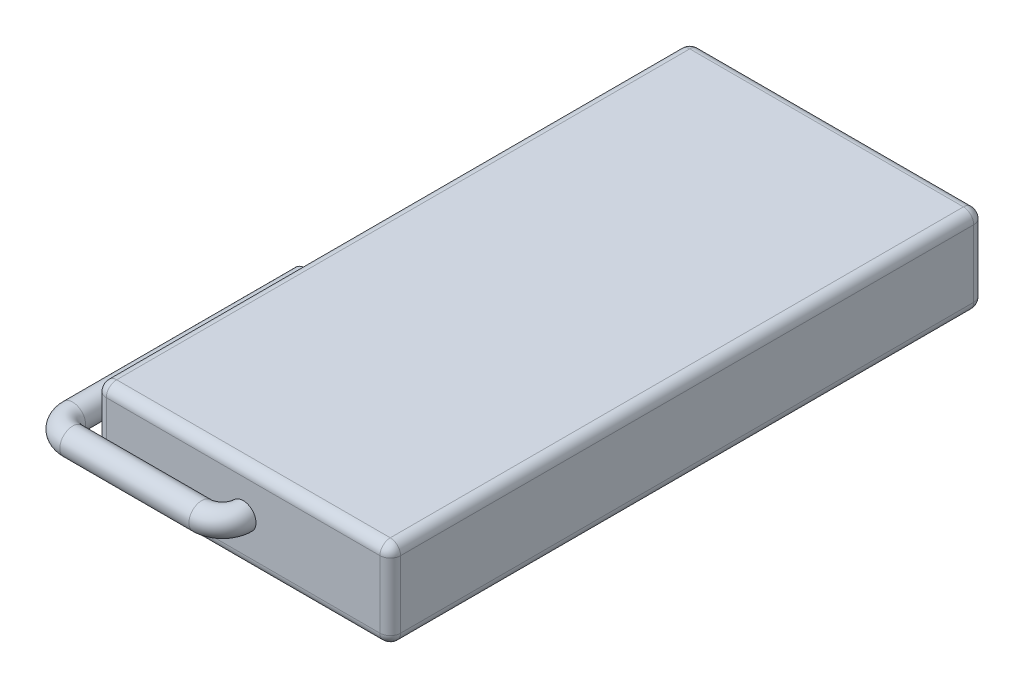
from build123d import *

# Parameters (mm, degrees)
SKETCH_1_W      = 57
SKETCH_1_H      = 115
EXTRUDE_1_DEPTH = 8.5
FILLET_1_R      = 2
SKETCH_3_R      = 2.5


with BuildPart() as part:
    # 草图1 → 凸台-拉伸1 (new body, symmetric)
    with BuildSketch(Plane(origin=(0, 0, 0), x_dir=(1, 0, 0), z_dir=(0, 1, 0))):
        Rectangle(SKETCH_1_W, SKETCH_1_H)
    extrude(amount=EXTRUDE_1_DEPTH, both=True)

    # 圆角1
    fillet_1_edges = [part.edges().sort_by_distance(p)[0] for p in [
        (28.5, 8.5, 0),
        (0, 8.5, -57.5),
        (-28.5, 8.5, 0),
        (0, -8.5, -57.5),
        (28.5, -8.5, 0),
        (0, -8.5, 57.5),
        (-28.5, -8.5, 0),
        (0, 8.5, 57.5),
        (-28.5, 0, -57.5),
        (28.5, 0, -57.5),
        (28.5, 0, 57.5),
        (-28.5, 0, 57.5),
    ]]
    fillet(fillet_1_edges, radius=FILLET_1_R)

    # 扫描1: sweep along a path in 草图2
    with BuildLine(Plane(origin=(0, 0, 0), x_dir=(1, 0, 0), z_dir=(0, 1, 0))) as sweep_1_path:
        Line((-33, -12.5), (-33, -57.5))
        ThreePointArc((-33, -57.5), (-31.828427125, -60.328427125), (-29, -61.5))
        Line((-29, -61.5), (-4, -61.5))
        ThreePointArc((-4, -61.5), (-1.171572875, -60.328427125), (0, -57.5))
    # 草图3 → 扫描1 (sweep)
    with BuildSketch(Plane.XY.offset(57.5)):
        Circle(SKETCH_3_R)
    sweep(path=sweep_1_path.line)


solid = part.part
